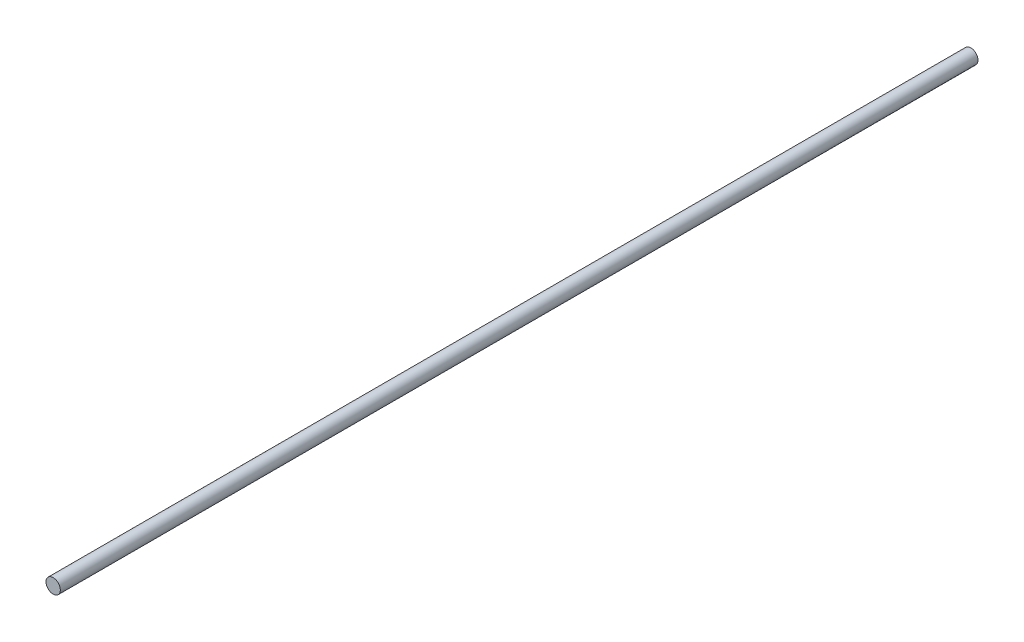
from build123d import *

# Parameters (mm, degrees)
SKETCH1_R           = 4
BOSS_EXTRUDE1_DEPTH = 512


with BuildPart() as part:
    # Sketch1 → Boss-Extrude1 (new body)
    with BuildSketch(Plane.XY):
        Circle(SKETCH1_R)
    extrude(amount=BOSS_EXTRUDE1_DEPTH)


solid = part.part
